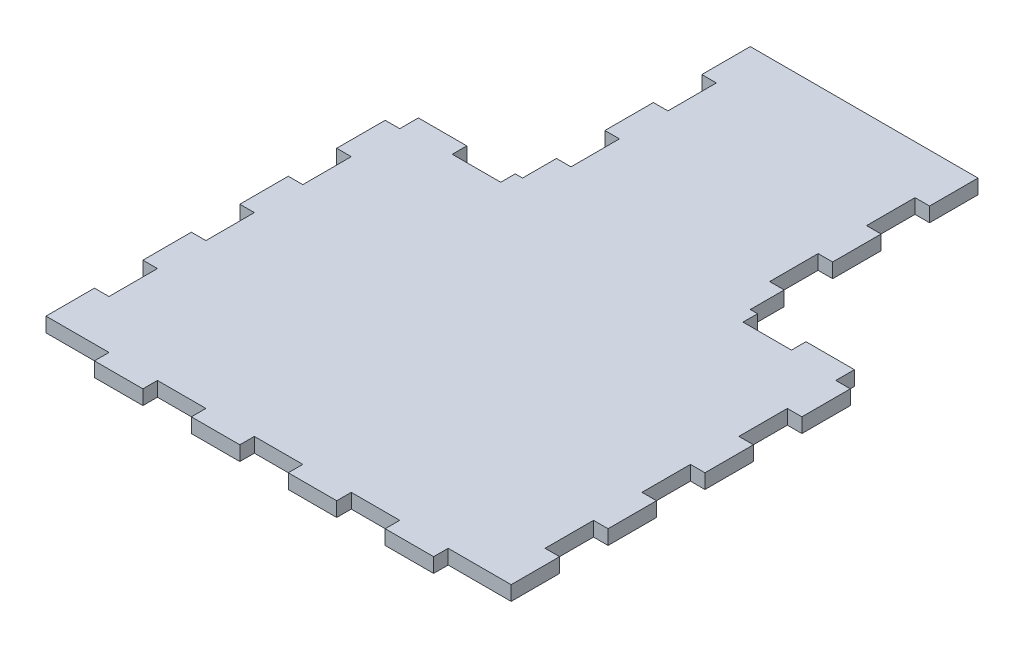
from build123d import *

# Parameters (mm, degrees)
BOSS_EXTRUDE1_DEPTH     = 3
SKETCH3_W               = 10
SKETCH3_H               = 3
BOSS_EXTRUDE2_DEPTH     = 3
LPATTERN1_COUNT         = 3
LPATTERN1_PITCH         = 20
SKETCH4_W               = 10
SKETCH4_H               = 3
BOSS_EXTRUDE3_DEPTH     = 3
LPATTERN2_COUNT         = 2
LPATTERN2_PITCH         = 20
SKETCH5_W               = 10
SKETCH5_H               = 3
BOSS_EXTRUDE4_DEPTH     = 3
LPATTERN3_COUNT         = 4
LPATTERN3_PITCH         = 20
SKETCH6_W               = 10
SKETCH6_H               = 3
BOSS_EXTRUDE5_DEPTH     = 3
LPATTERN4_COUNT         = 2
LPATTERN4_PITCH         = 20
MIRROR3_COPY_1_SKETCH_W = 10
MIRROR3_COPY_1_SKETCH_H = 3
MIRROR3_COPY_1_DEPTH    = 3
MIRROR3_COPY_2_SKETCH_W = 10
MIRROR3_COPY_2_SKETCH_H = 3
MIRROR3_COPY_2_DEPTH    = 3
MIRROR3_COPY_3_SKETCH_W = 10
MIRROR3_COPY_3_SKETCH_H = 3
MIRROR3_COPY_3_DEPTH    = 3
MIRROR3_COPY_4_SKETCH_W = 10
MIRROR3_COPY_4_SKETCH_H = 3
MIRROR3_COPY_4_DEPTH    = 3
MIRROR3_COPY_5_SKETCH_W = 10
MIRROR3_COPY_5_SKETCH_H = 3
MIRROR3_COPY_5_DEPTH    = 3
MIRROR3_COPY_6_SKETCH_W = 10
MIRROR3_COPY_6_SKETCH_H = 3
MIRROR3_COPY_6_DEPTH    = 3
MIRROR3_COPY_7_SKETCH_W = 10
MIRROR3_COPY_7_SKETCH_H = 3
MIRROR3_COPY_7_DEPTH    = 3


with BuildPart() as part:
    # Sketch1 → Boss-Extrude1 (new body)
    with BuildSketch(Plane(origin=(0, 0, 0), x_dir=(1, 0, 0), z_dir=(0, 1, 0))):
        Polygon((20.5, 60.804597701), (-20.5, 60.804597701), (-20.5, 10.804597701), (-45, 10.804597701), (-45, -60.045977011), (45, -60.045977011), (45, 10.804597701), (20.5, 10.804597701), align=None)
    extrude(amount=BOSS_EXTRUDE1_DEPTH)

    # Sketch3 → Boss-Extrude2 (add)
    with BuildSketch(Plane.ZY.offset(20.5)):
        with Locations((-55.804597701, 1.5)):
            Rectangle(SKETCH3_W, SKETCH3_H)
    boss_extrude2 = extrude(amount=BOSS_EXTRUDE2_DEPTH)

    # LPattern1: Boss-Extrude2 ×3
    with Locations(*[(0, 0, i * LPATTERN1_PITCH) for i in range(1, LPATTERN1_COUNT)]):
        add(boss_extrude2)

    # Sketch4 → Boss-Extrude3 (add)
    with BuildSketch(Plane(origin=(0, 0, -10.804597701), x_dir=(-1, 0, 0), z_dir=(0, 0, -1))):
        with Locations((-40, 1.5)):
            Rectangle(SKETCH4_W, SKETCH4_H)
    boss_extrude3 = extrude(amount=BOSS_EXTRUDE3_DEPTH)

    # LPattern2: Boss-Extrude3 ×2
    with Locations(*[(-i * LPATTERN2_PITCH, 0, 0) for i in range(1, LPATTERN2_COUNT)]):
        add(boss_extrude3)

    # Sketch5 → Boss-Extrude4 (add)
    with BuildSketch(Plane(origin=(45, 0, 0), x_dir=(0, 0, -1), z_dir=(1, 0, 0))):
        with Locations((-55.045977011, 1.5)):
            Rectangle(SKETCH5_W, SKETCH5_H)
    boss_extrude4 = extrude(amount=BOSS_EXTRUDE4_DEPTH)

    # LPattern3: Boss-Extrude4 ×4
    with Locations(*[(0, 0, -i * LPATTERN3_PITCH) for i in range(1, LPATTERN3_COUNT)]):
        add(boss_extrude4)

    # Sketch6 → Boss-Extrude5 (add)
    with BuildSketch(Plane.XY.offset(60.045977011)):
        with Locations((10, 1.5)):
            Rectangle(SKETCH6_W, SKETCH6_H)
    boss_extrude5 = extrude(amount=BOSS_EXTRUDE5_DEPTH)

    # LPattern4: Boss-Extrude5 ×2
    with Locations(*[(i * LPATTERN4_PITCH, 0, 0) for i in range(1, LPATTERN4_COUNT)]):
        add(boss_extrude5)

    # Mirror3: Boss-Extrude2, Boss-Extrude3, Boss-Extrude4, Boss-Extrude5 across plane
    add(boss_extrude2.mirror(Plane.ZY))
    add(boss_extrude3.mirror(Plane.ZY))
    add(boss_extrude4.mirror(Plane.ZY))
    add(boss_extrude5.mirror(Plane.ZY))

    # Mirror3 copy 1 sketch → Mirror3 copy 1 (add)
    with BuildSketch(Plane(origin=(20, 0, -10.804597701), x_dir=(1, 0, 0), z_dir=(0, 0, -1))):
        with Locations((-40, -1.5)):
            Rectangle(MIRROR3_COPY_1_SKETCH_W, MIRROR3_COPY_1_SKETCH_H)
    extrude(amount=MIRROR3_COPY_1_DEPTH)

    # Mirror3 copy 2 sketch → Mirror3 copy 2 (add)
    with BuildSketch(Plane(origin=(-20, 0, 60.045977011), x_dir=(-1, 0, 0), z_dir=(0, 0, 1))):
        with Locations((10, -1.5)):
            Rectangle(MIRROR3_COPY_2_SKETCH_W, MIRROR3_COPY_2_SKETCH_H)
    extrude(amount=MIRROR3_COPY_2_DEPTH)

    # Mirror3 copy 3 sketch → Mirror3 copy 3 (add)
    with BuildSketch(Plane(origin=(-45, 0, -20), x_dir=(0, 0, -1), z_dir=(-1, 0, 0))):
        with Locations((-55.045977011, -1.5)):
            Rectangle(MIRROR3_COPY_3_SKETCH_W, MIRROR3_COPY_3_SKETCH_H)
    extrude(amount=MIRROR3_COPY_3_DEPTH)

    # Mirror3 copy 4 sketch → Mirror3 copy 4 (add)
    with BuildSketch(Plane(origin=(-45, 0, -40), x_dir=(0, 0, -1), z_dir=(-1, 0, 0))):
        with Locations((-55.045977011, -1.5)):
            Rectangle(MIRROR3_COPY_4_SKETCH_W, MIRROR3_COPY_4_SKETCH_H)
    extrude(amount=MIRROR3_COPY_4_DEPTH)

    # Mirror3 copy 5 sketch → Mirror3 copy 5 (add)
    with BuildSketch(Plane(origin=(-45, 0, -60), x_dir=(0, 0, -1), z_dir=(-1, 0, 0))):
        with Locations((-55.045977011, -1.5)):
            Rectangle(MIRROR3_COPY_5_SKETCH_W, MIRROR3_COPY_5_SKETCH_H)
    extrude(amount=MIRROR3_COPY_5_DEPTH)

    # Mirror3 copy 6 sketch → Mirror3 copy 6 (add)
    with BuildSketch(Plane(origin=(20.5, 0, 20), x_dir=(0, 0, 1), z_dir=(1, 0, 0))):
        with Locations((-55.804597701, -1.5)):
            Rectangle(MIRROR3_COPY_6_SKETCH_W, MIRROR3_COPY_6_SKETCH_H)
    extrude(amount=MIRROR3_COPY_6_DEPTH)

    # Mirror3 copy 7 sketch → Mirror3 copy 7 (add)
    with BuildSketch(Plane(origin=(20.5, 0, 40), x_dir=(0, 0, 1), z_dir=(1, 0, 0))):
        with Locations((-55.804597701, -1.5)):
            Rectangle(MIRROR3_COPY_7_SKETCH_W, MIRROR3_COPY_7_SKETCH_H)
    extrude(amount=MIRROR3_COPY_7_DEPTH)


solid = part.part
